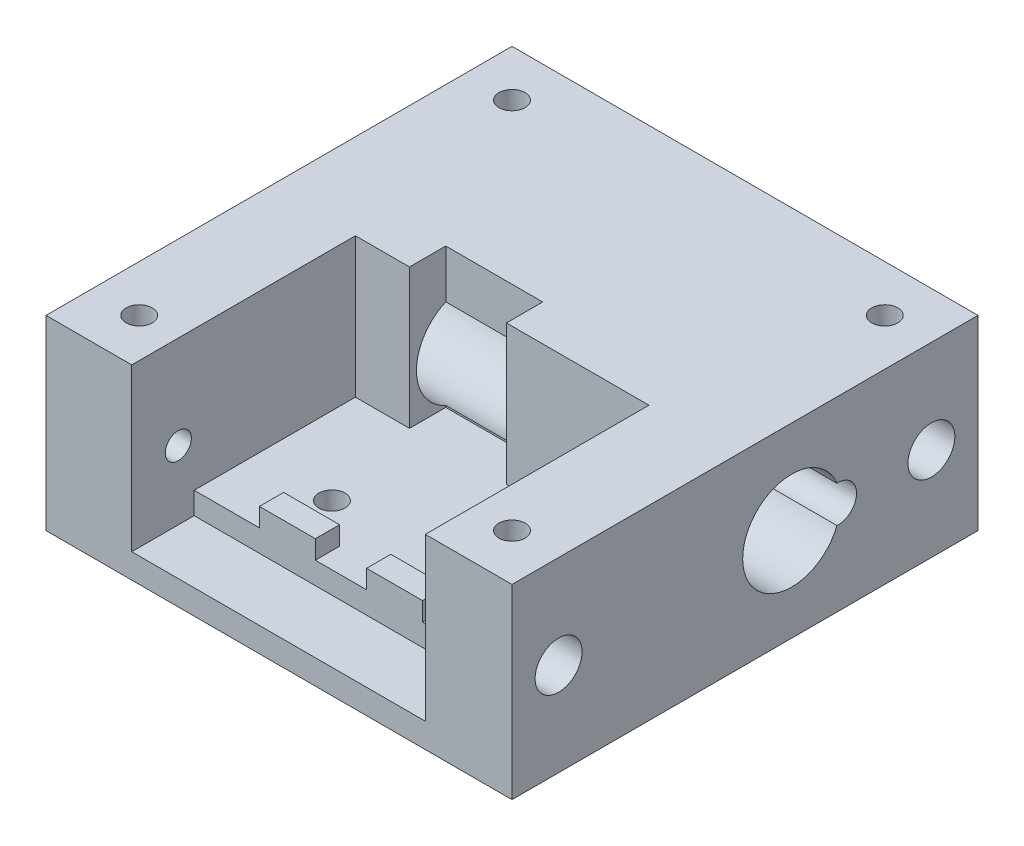
from build123d import *

# Parameters (mm, degrees)
SKETCH1_W                      = 31.75
SKETCH1_H                      = 31.75
MAIN_BODY_DEPTH                = 12.7
CUT_EXTRUDE1_DEPTH             = 9.525
SKETCH3_W                      = 20
SKETCH3_H                      = 4.2545
CUT_EXTRUDE2_DEPTH             = 1.5
SKETCH4_W                      = 3.81
SKETCH4_H                      = 1.651
BOSS_EXTRUDE2_DEPTH            = 1.27
SKETCH5_R                      = 3.33375
CUT_EXTRUDE3_DEPTH             = 32.75
SKETCH6_R                      = 1.25000004
CUT_EXTRUDE4_DEPTH             = 20.32
TAP_DRILL_FOR_2_56_TAP1_D      = 1.778
TAP_DRILL_FOR_2_56_TAP2_D      = 1.778
F_3_2_3_2_DIAMETER_HOLE1_D     = 3.2
F_3_2_3_2_DIAMETER_HOLE1_DEPTH = 6.15062301
F_3_2_3_2_DIAMETER_HOLE1_TIP   = 0.96137699
TAP_DRILL_FOR_2_56_TAP4_D      = 1.778
TAP_DRILL_FOR_2_56_TAP4_DEPTH  = 6.57783491
TAP_DRILL_FOR_2_56_TAP4_TIP    = 0.53416509


with BuildPart() as part:
    # Sketch1 → Main body (new body)
    with BuildSketch(Plane(origin=(0, 0, 0), x_dir=(1, 0, 0), z_dir=(0, 1, 0))):
        with Locations((15.875, 15.875)):
            Rectangle(SKETCH1_W, SKETCH1_H)
    extrude(amount=MAIN_BODY_DEPTH)

    # Sketch2 → Cut-Extrude1 (cut)
    with BuildSketch(Plane(origin=(0, 12.7, 0), x_dir=(1, 0, 0), z_dir=(0, 1, 0))):
        Polygon((5.842, 0), (5.842, 15.24), (9.525, 15.24), (9.525, 17.712672935), (16.129, 17.712672935), (16.129, 15.24), (25.842, 15.24), (25.842, 0), align=None)
    extrude(amount=-CUT_EXTRUDE1_DEPTH, mode=Mode.SUBTRACT)

    # Sketch3 → Cut-Extrude2 (cut)
    with BuildSketch(Plane(origin=(0, 3.175, 0), x_dir=(1, 0, 0), z_dir=(0, 1, 0))):
        with Locations((15.842, 2.12725)):
            Rectangle(SKETCH3_W, SKETCH3_H)
    extrude(amount=-CUT_EXTRUDE2_DEPTH, mode=Mode.SUBTRACT)

    # Sketch4 → Boss-Extrude2 (add)
    with BuildSketch(Plane(origin=(0, 3.175, 0), x_dir=(1, 0, 0), z_dir=(0, 1, 0))):
        with Locations((12.192, 5.08)):
            Rectangle(SKETCH4_W, SKETCH4_H)
        with Locations((19.492, 5.08)):
            Rectangle(SKETCH4_W, SKETCH4_H)
    extrude(amount=BOSS_EXTRUDE2_DEPTH)

    # Sketch5 → Cut-Extrude3 (cut, through all)
    with BuildSketch(Plane.ZY):
        with Locations((-19.05, 6.35)):
            Circle(SKETCH5_R)
    extrude(amount=-CUT_EXTRUDE3_DEPTH, mode=Mode.SUBTRACT)

    # Sketch6 → Cut-Extrude4 (cut)
    with BuildSketch(Plane.ZY.offset(-31.75)):
        with Locations((-22.225, 6.35)):
            Circle(SKETCH6_R)
    extrude(amount=CUT_EXTRUDE4_DEPTH, mode=Mode.SUBTRACT)

    # Tap Drill for #2-56 Tap1 (through all)
    with Locations(Plane(origin=(0, 0, 0), x_dir=(-1, 0, 0), z_dir=(0, -1, 0))):
        with Locations((-28.575, 3.175), (-28.575, 28.575), (-3.175, 3.175), (-3.175, 28.575)):
            Hole(TAP_DRILL_FOR_2_56_TAP1_D / 2)

    # Tap Drill for #2-56 Tap2 (through all)
    with Locations(Plane(origin=(0, 3.175, 0), x_dir=(1, 0, 0), z_dir=(0, 1, 0))):
        with Locations((20.642, 8.34), (11.142, 8.34)):
            Hole(TAP_DRILL_FOR_2_56_TAP2_D / 2)

    # Ø3.2 (3.2) Diameter Hole1
    with Locations(Plane(origin=(31.75, 0, 0), x_dir=(0, 0, -1), z_dir=(1, 0, 0))):
        with Locations((28.575, 6.35), (3.175, 6.35)):
            Hole(F_3_2_3_2_DIAMETER_HOLE1_D / 2, depth=F_3_2_3_2_DIAMETER_HOLE1_DEPTH)
            with Locations((0, 0, -(F_3_2_3_2_DIAMETER_HOLE1_DEPTH + F_3_2_3_2_DIAMETER_HOLE1_TIP / 2))):  # 118° drill point
                Cone(0, F_3_2_3_2_DIAMETER_HOLE1_D / 2, F_3_2_3_2_DIAMETER_HOLE1_TIP, mode=Mode.SUBTRACT)

    # Tap Drill for #2-56 Tap4
    with Locations(Plane.ZY):
        with Locations((-3.175, 6.35), (-28.575, 6.35)):
            Hole(TAP_DRILL_FOR_2_56_TAP4_D / 2, depth=TAP_DRILL_FOR_2_56_TAP4_DEPTH)
            with Locations((0, 0, -(TAP_DRILL_FOR_2_56_TAP4_DEPTH + TAP_DRILL_FOR_2_56_TAP4_TIP / 2))):  # 118° drill point
                Cone(0, TAP_DRILL_FOR_2_56_TAP4_D / 2, TAP_DRILL_FOR_2_56_TAP4_TIP, mode=Mode.SUBTRACT)


solid = part.part
